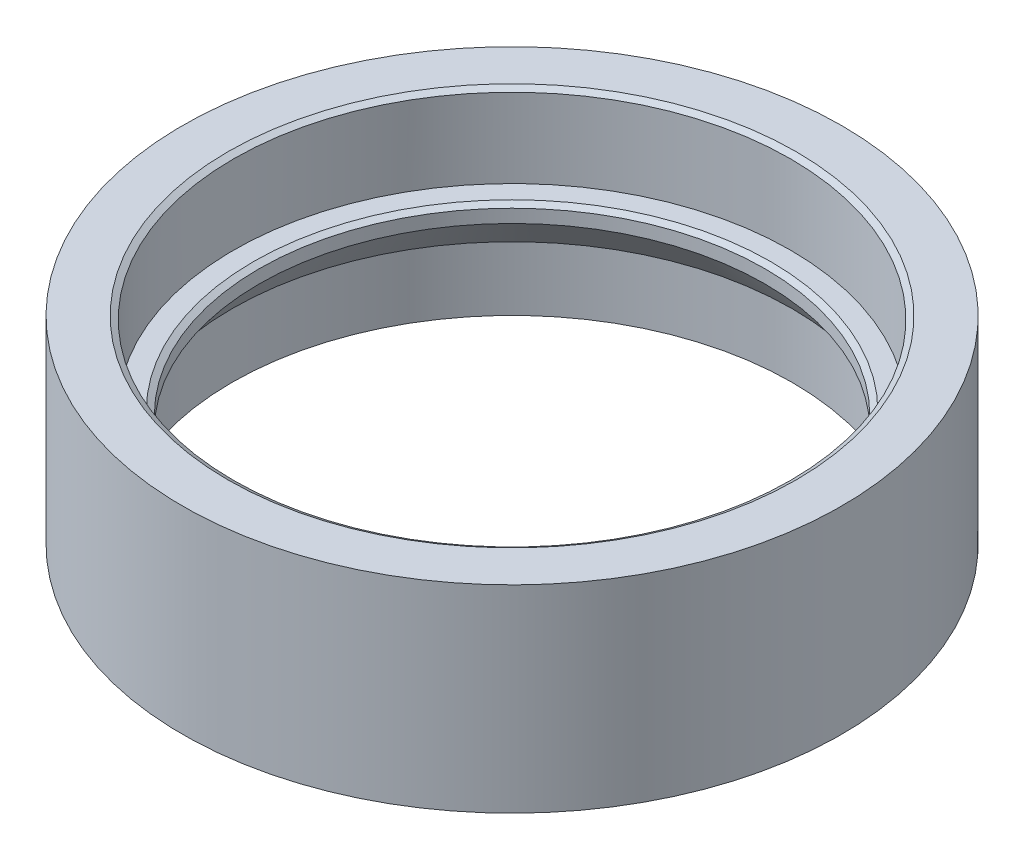
from build123d import *

# Parameters (mm, degrees)
CHAMFER2_SIZE         = 1
CHAMFER2_SIZE2        = 1.732050808
CHAMFER2_PART_2_SIZE  = 1
CHAMFER2_PART_2_SIZE2 = 1.732050808
FILLET1_R             = 1


with BuildPart() as part:
    # Sketch1 → Revolve1 (revolve)
    with BuildSketch(Plane.XY):
        Polygon((84.5, 60), (100, 60), (100, 0), (95, 0), (95, 5), (89.9, 5), (89.9, 0), (84.99, 0), (84.99, 19.369395797), (76.75, 30), (76.75, 35), (84.5, 35), align=None)
    revolve(axis=Axis((0, 0, 0), (0, 1, 0)))

    # Chamfer2
    chamfer2_edges = [part.edges().sort_by_distance(p)[0] for p in [
        (-84.5, 60, 0),
    ]]
    chamfer2_side = [part.faces().sort_by_distance(p)[0] for p in [
        (-84.5, 47.5, 0),
    ]]
    chamfer(chamfer2_edges, length=CHAMFER2_SIZE, length2=CHAMFER2_SIZE2, reference=chamfer2_side[0])

    # Chamfer2 part 2
    chamfer2_part_2_edges = [part.edges().sort_by_distance(p)[0] for p in [
        (-76.75, 35, 0),
    ]]
    chamfer2_part_2_side = [part.faces().sort_by_distance(p)[0] for p in [
        (-76.75, 32.5, 0),
    ]]
    chamfer(chamfer2_part_2_edges, length=CHAMFER2_PART_2_SIZE, length2=CHAMFER2_PART_2_SIZE2, reference=chamfer2_part_2_side[0])

    # Fillet1
    fillet1_edges = [part.edges().sort_by_distance(p)[0] for p in [
        (-95, 0, 0),
        (-89.9, 0, 0),
    ]]
    fillet(fillet1_edges, radius=FILLET1_R)


solid = part.part
